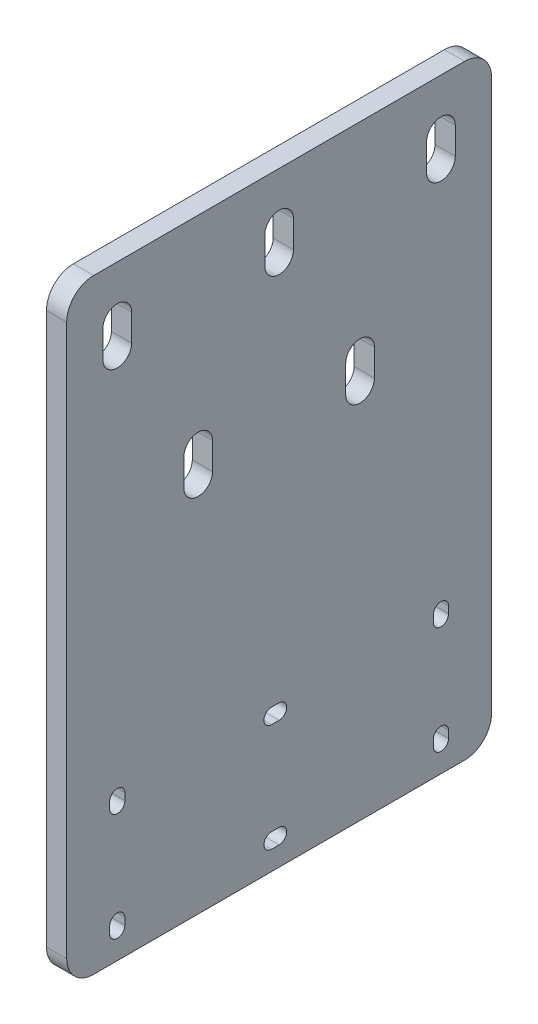
from build123d import *

# Parameters (mm, degrees)
EXTRUDE_2_DEPTH          = 6
CUT_EXTRUDE_1_DEPTH      = 7
CUT_EXTRUDE_1_DEPTH_BACK = 1


with BuildPart() as part:
    # 草图1 → 凸台-拉伸2 (new body)
    with BuildSketch(Plane(origin=(0, 0, 0), x_dir=(0, 0, -1), z_dir=(1, 0, 0))):
        with BuildLine():
            Line((8, 0), (118, 0))
            ThreePointArc((118, 0), (123.656854249, 2.343145751), (126, 8))
            Line((126, 8), (126, 171.5))
            ThreePointArc((126, 171.5), (123.656854249, 177.156854249), (118, 179.5))
            Line((118, 179.5), (8, 179.5))
            ThreePointArc((8, 179.5), (2.343145751, 177.156854249), (0, 171.5))
            Line((0, 171.5), (0, 8))
            ThreePointArc((0, 8), (2.343145751, 2.343145751), (8, 0))
        make_face()
        with BuildLine():
            Line((12.75, 10), (12.75, 8))
            ThreePointArc((12.75, 8), (15, 5.75), (17.25, 8))
            Line((17.25, 8), (17.25, 10))
            ThreePointArc((17.25, 10), (15, 12.25), (12.75, 10))
        make_face(mode=Mode.SUBTRACT)
        with BuildLine():
            Line((12.75, 42), (12.75, 40))
            ThreePointArc((12.75, 40), (15, 37.75), (17.25, 40))
            Line((17.25, 40), (17.25, 42))
            ThreePointArc((17.25, 42), (15, 44.25), (12.75, 42))
        make_face(mode=Mode.SUBTRACT)
        with BuildLine():
            Line((108.75, 42), (108.75, 40))
            ThreePointArc((108.75, 40), (111, 37.75), (113.25, 40))
            Line((113.25, 40), (113.25, 42))
            ThreePointArc((113.25, 42), (111, 44.25), (108.75, 42))
        make_face(mode=Mode.SUBTRACT)
        with BuildLine():
            Line((108.75, 10), (108.75, 8))
            ThreePointArc((108.75, 8), (111, 5.75), (113.25, 8))
            Line((113.25, 8), (113.25, 10))
            ThreePointArc((113.25, 10), (111, 12.25), (108.75, 10))
        make_face(mode=Mode.SUBTRACT)
        with BuildLine():
            Line((60.75, 37.75), (63, 37.75))
            ThreePointArc((63, 37.75), (65.25, 40), (63, 42.25))
            Line((63, 42.25), (60.75, 42.25))
            ThreePointArc((60.75, 42.25), (58.5, 40), (60.75, 37.75))
        make_face(mode=Mode.SUBTRACT)
        with BuildLine():
            Line((60.75, 10.25), (63, 10.25))
            ThreePointArc((63, 10.25), (65.25, 8), (63, 5.75))
            Line((63, 5.75), (60.75, 5.75))
            ThreePointArc((60.75, 5.75), (58.5, 8), (60.75, 10.25))
        make_face(mode=Mode.SUBTRACT)
        with BuildLine():
            Line((34.75, 116.5), (34.75, 119.5))
            ThreePointArc((34.75, 119.5), (39, 123.75), (43.25, 119.5))
            Line((43.25, 119.5), (43.25, 116.5))
            ThreePointArc((43.25, 116.5), (39, 112.25), (34.75, 116.5))
        make_face(mode=Mode.SUBTRACT)
        with BuildLine():
            Line((82.75, 116.5), (82.75, 119.5))
            ThreePointArc((82.75, 119.5), (87, 123.75), (91.25, 119.5))
            Line((91.25, 119.5), (91.25, 116.5))
            ThreePointArc((91.25, 116.5), (87, 112.25), (82.75, 116.5))
        make_face(mode=Mode.SUBTRACT)
        with BuildLine():
            Line((10.75, 164.5), (10.75, 161.5))
            ThreePointArc((10.75, 161.5), (15, 157.25), (19.25, 161.5))
            Line((19.25, 161.5), (19.25, 164.5))
            ThreePointArc((19.25, 164.5), (15, 168.75), (10.75, 164.5))
        make_face(mode=Mode.SUBTRACT)
        with BuildLine():
            Line((67.25, 164.5), (67.25, 161.5))
            ThreePointArc((67.25, 161.5), (63, 157.25), (58.75, 161.5))
            Line((58.75, 161.5), (58.75, 164.5))
            ThreePointArc((58.75, 164.5), (63, 168.75), (67.25, 164.5))
        make_face(mode=Mode.SUBTRACT)
        with BuildLine():
            Line((115.25, 164.5), (115.25, 161.5))
            ThreePointArc((115.25, 161.5), (111, 157.25), (106.75, 161.5))
            Line((106.75, 161.5), (106.75, 164.5))
            ThreePointArc((106.75, 164.5), (111, 168.75), (115.25, 164.5))
        make_face(mode=Mode.SUBTRACT)
    extrude(amount=EXTRUDE_2_DEPTH)

    # 草图2 → 切除-拉伸1 (cut, two sides)
    with BuildSketch(Plane(origin=(0, 0, 0), x_dir=(0, 0, -1), z_dir=(1, 0, 0))) as cut_extrude_1_sk:
        with BuildLine():
            Line((43.25, 119.5), (43.25, 111.5))
            ThreePointArc((43.25, 111.5), (39, 107.25), (34.75, 111.5))
            Line((34.75, 111.5), (34.75, 119.5))
            ThreePointArc((34.75, 119.5), (39, 123.75), (43.25, 119.5))
        make_face()
        with BuildLine():
            Line((91.25, 119.5), (91.25, 111.5))
            ThreePointArc((91.25, 111.5), (87, 107.25), (82.75, 111.5))
            Line((82.75, 111.5), (82.75, 119.5))
            ThreePointArc((82.75, 119.5), (87, 123.75), (91.25, 119.5))
        make_face()
        with BuildLine():
            Line((19.25, 164.5), (19.25, 156.5))
            ThreePointArc((19.25, 156.5), (15, 152.25), (10.75, 156.5))
            Line((10.75, 156.5), (10.75, 164.5))
            ThreePointArc((10.75, 164.5), (15, 168.75), (19.25, 164.5))
        make_face()
        with BuildLine():
            Line((67.25, 164.5), (67.25, 156.5))
            ThreePointArc((67.25, 156.5), (63, 152.25), (58.75, 156.5))
            Line((58.75, 156.5), (58.75, 164.5))
            ThreePointArc((58.75, 164.5), (63, 168.75), (67.25, 164.5))
        make_face()
        with BuildLine():
            Line((115.25, 164.5), (115.25, 156.5))
            ThreePointArc((115.25, 156.5), (111, 152.25), (106.75, 156.5))
            Line((106.75, 156.5), (106.75, 164.5))
            ThreePointArc((106.75, 164.5), (111, 168.75), (115.25, 164.5))
        make_face()
    extrude(amount=CUT_EXTRUDE_1_DEPTH, mode=Mode.SUBTRACT)
    extrude(cut_extrude_1_sk.sketch, amount=-CUT_EXTRUDE_1_DEPTH_BACK, mode=Mode.SUBTRACT)


solid = part.part
